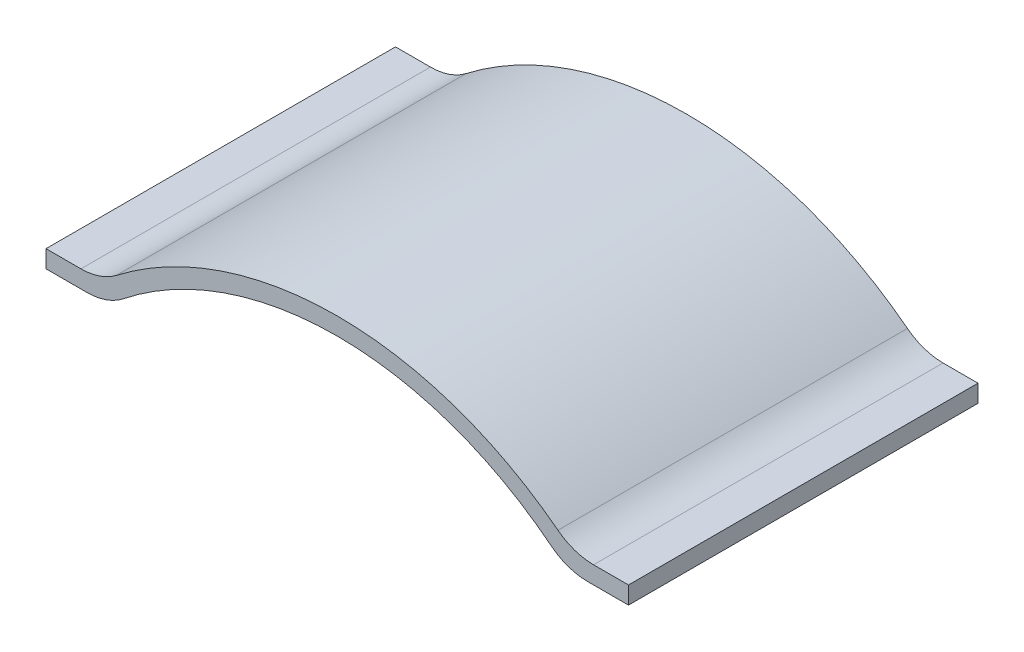
from build123d import *

# Parameters (mm, degrees)
BOSS_EXTRUDE1_DEPTH = 60


with BuildPart() as part:
    # Sketch1 → Boss-Extrude1 (new body)
    with BuildSketch(Plane.XY):
        with BuildLine():
            Line((0, 0), (0, -3))
            Line((0, -3), (7.034897882, -3))
            ThreePointArc((7.034897882, -3), (10.331004184, -2.441169591), (13.2587176, -0.827136649))
            ThreePointArc((13.2587176, -0.827136649), (50, 12), (86.7412824, -0.827136649))
            ThreePointArc((86.7412824, -0.827136649), (89.668995816, -2.441169591), (92.965102118, -3))
            Line((92.965102118, -3), (100, -3))
            Line((100, -3), (100, 0))
            Line((100, 0), (94, 0))
            ThreePointArc((94, 0), (90.773260722, 0.534898118), (87.891716798, 2.082369273))
            ThreePointArc((87.891716798, 2.082369273), (50, 15), (12.108283202, 2.082369273))
            ThreePointArc((12.108283202, 2.082369273), (9.226739278, 0.534898118), (6, 0))
            Line((6, 0), (0, 0))
        make_face()
    extrude(amount=BOSS_EXTRUDE1_DEPTH)


solid = part.part
